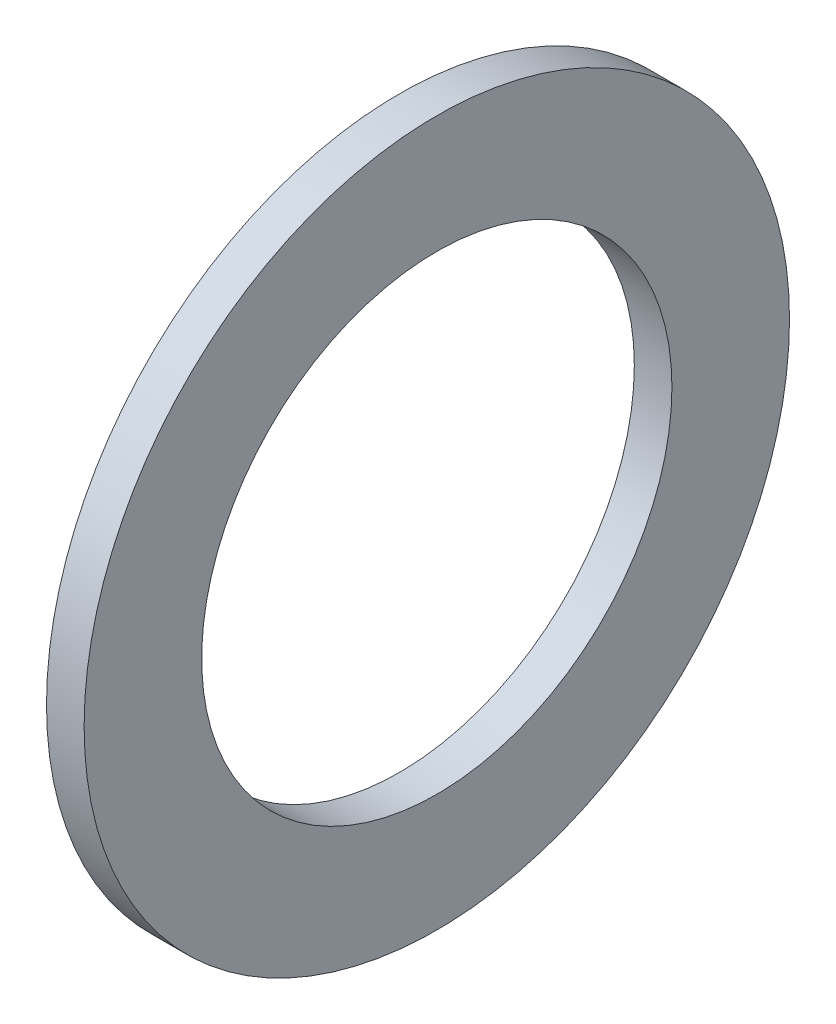
from build123d import *

# Parameters (mm, degrees)
SKETCH1_R           = 4.7625
SKETCH1_R_2         = 3.175
BOSS_EXTRUDE1_DEPTH = 0.508


with BuildPart() as part:
    # Sketch1 → Boss-Extrude1 (new body)
    with BuildSketch(Plane(origin=(0, 0, 0), x_dir=(0, 0, -1), z_dir=(1, 0, 0))):
        Circle(SKETCH1_R)
        Circle(SKETCH1_R_2, mode=Mode.SUBTRACT)
    extrude(amount=BOSS_EXTRUDE1_DEPTH)


solid = part.part
